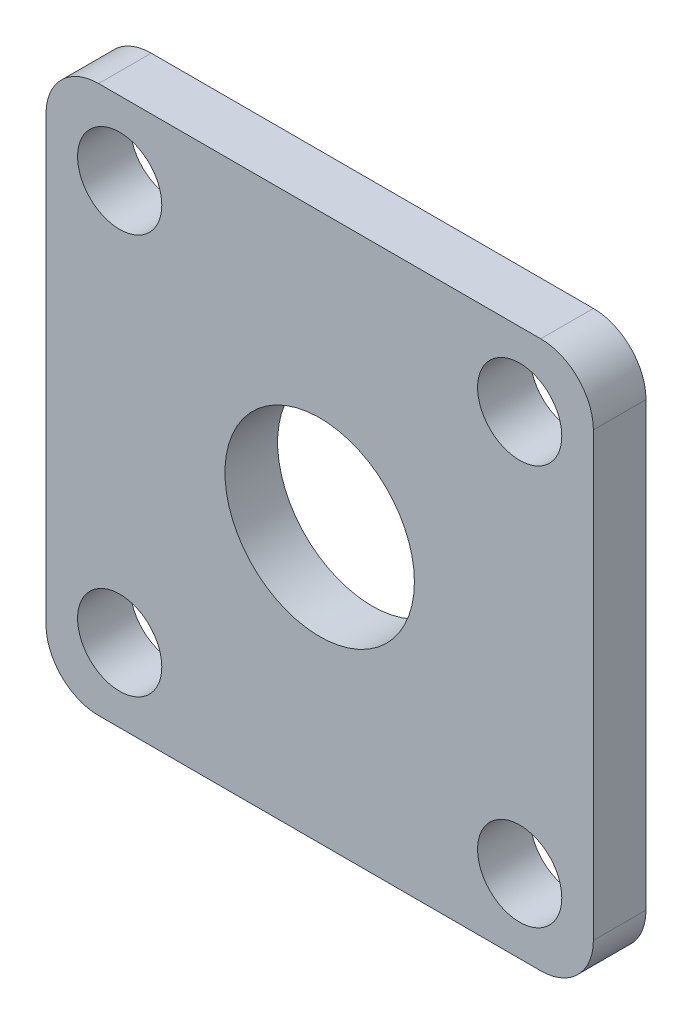
from build123d import *

# Parameters (mm, degrees)
SCHIZZO1_R                   = 4
SCHIZZO1_R_2                 = 9
ESTRUSIONE_ESTRUSIONE1_DEPTH = 5


with BuildPart() as part:
    # Schizzo1 → Estrusione-Estrusione1 (new body)
    with BuildSketch(Plane.XY):
        with BuildLine():
            Line((5, 52), (47, 52))
            ThreePointArc((47, 52), (50.535533906, 50.535533906), (52, 47))
            Line((52, 47), (52, 5))
            ThreePointArc((52, 5), (50.535533906, 1.464466094), (47, 0))
            Line((47, 0), (5, 0))
            ThreePointArc((5, 0), (1.464466094, 1.464466094), (0, 5))
            Line((0, 5), (0, 47))
            ThreePointArc((0, 47), (1.464466094, 50.535533906), (5, 52))
        make_face()
        with Locations((7, 45)):
            Circle(SCHIZZO1_R, mode=Mode.SUBTRACT)
        with Locations((45, 45)):
            Circle(SCHIZZO1_R, mode=Mode.SUBTRACT)
        with Locations((7, 7)):
            Circle(SCHIZZO1_R, mode=Mode.SUBTRACT)
        with Locations((45, 7)):
            Circle(SCHIZZO1_R, mode=Mode.SUBTRACT)
        with Locations((26, 26)):
            Circle(SCHIZZO1_R_2, mode=Mode.SUBTRACT)
    extrude(amount=ESTRUSIONE_ESTRUSIONE1_DEPTH)


solid = part.part
